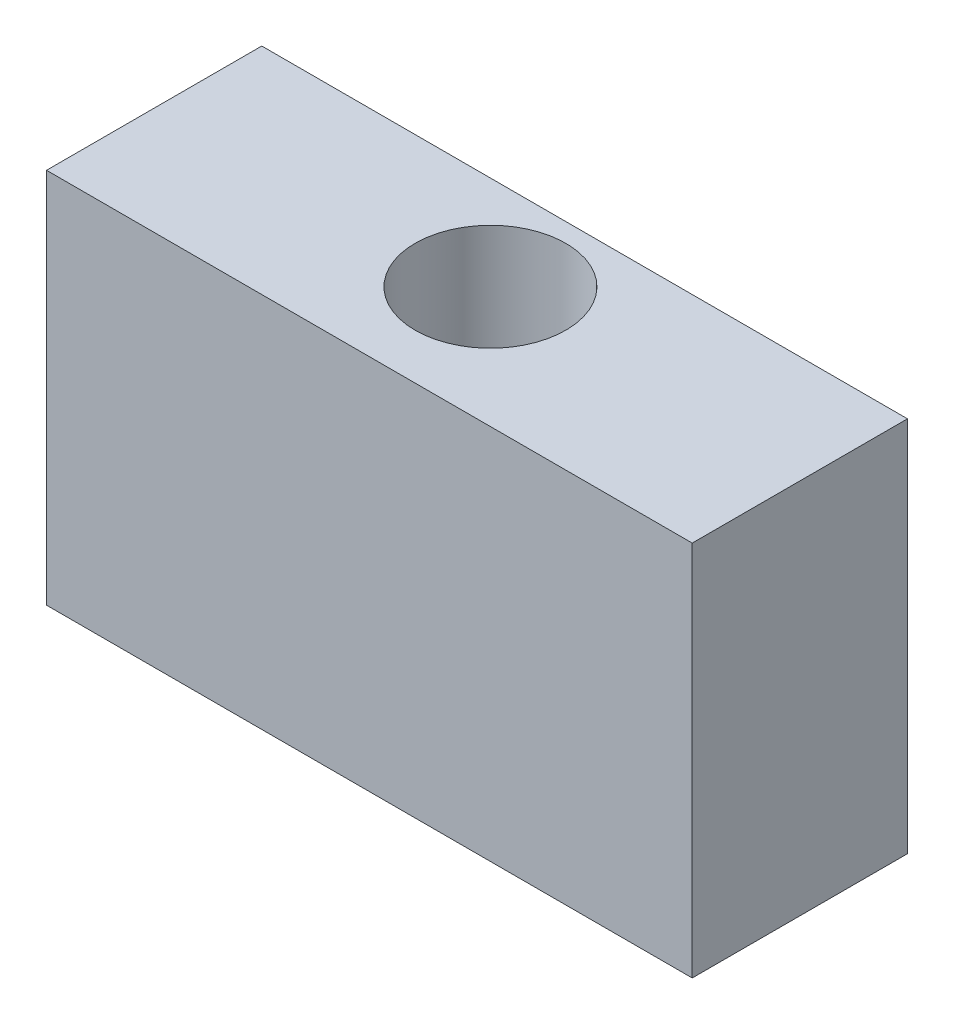
from build123d import *

# Parameters (mm, degrees)
SKETCH1_W           = 38.1
SKETCH1_H           = 12.7
SKETCH1_R           = 4.445
BOSS_EXTRUDE1_DEPTH = 22.225


with BuildPart() as part:
    # Sketch1 → Boss-Extrude1 (new body)
    with BuildSketch(Plane(origin=(0, 0, 0), x_dir=(1, 0, 0), z_dir=(0, 1, 0))):
        with Locations((19.05, 6.35)):
            Rectangle(SKETCH1_W, SKETCH1_H)
        with Locations((19.05, 7.14375)):
            Circle(SKETCH1_R, mode=Mode.SUBTRACT)
    extrude(amount=BOSS_EXTRUDE1_DEPTH)


solid = part.part
